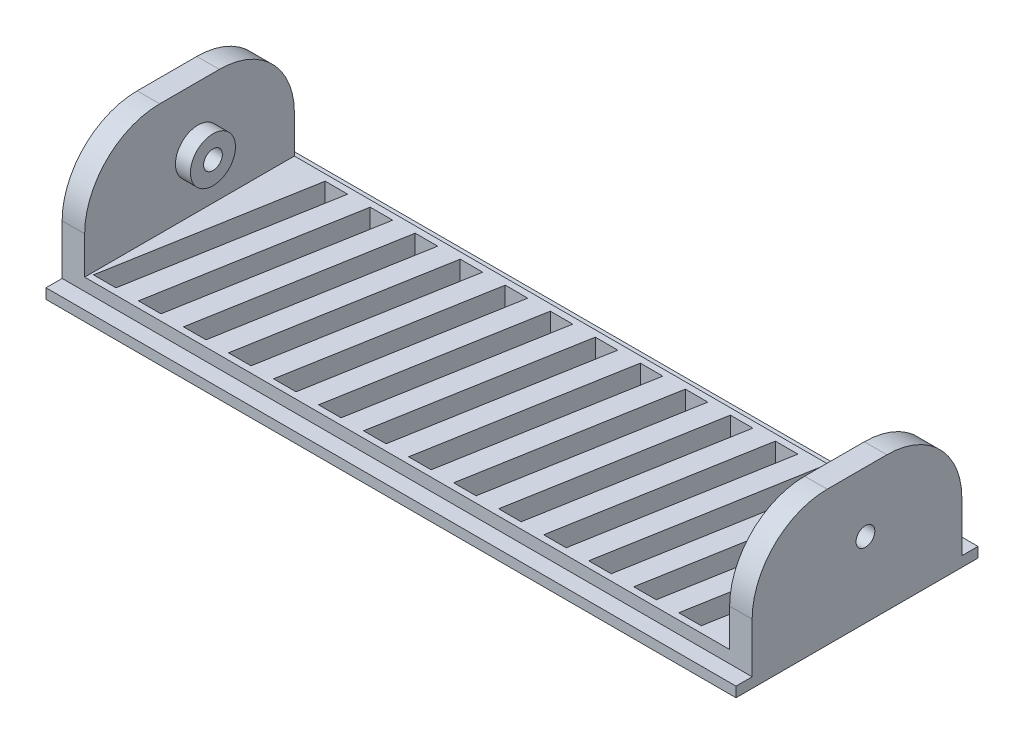
from build123d import *

# Parameters (mm, degrees)
SKETCH1_W               = 91.95
SKETCH1_H               = 32.25
BOSS_EXTRUDE1_DEPTH     = 3
SKETCH2_W               = 91.95
SKETCH2_H               = 2.15
CUT_EXTRUDE1_DEPTH      = 1.65
SKETCH4_W               = 3
SKETCH4_H               = 27.95
BOSS_EXTRUDE2_DEPTH     = 15
SKETCH5_R               = 1.25
CUT_EXTRUDE2_DEPTH      = 1
CUT_EXTRUDE2_DEPTH_BACK = 92.95
FILLET2_R               = 10
CUT_EXTRUDE5_REACH      = 20
SKETCH8_R               = 3
BOSS_EXTRUDE3_DEPTH     = 2
SKETCH9_R               = 1.25
CUT_EXTRUDE6_DEPTH      = 1
CUT_EXTRUDE6_DEPTH_BACK = 92.95


with BuildPart() as part:
    # Sketch1 → Boss-Extrude1 (new body)
    with BuildSketch(Plane(origin=(0, 0, 0), x_dir=(1, 0, 0), z_dir=(0, 1, 0))):
        with Locations((45.975, 16.125)):
            Rectangle(SKETCH1_W, SKETCH1_H)
    extrude(amount=BOSS_EXTRUDE1_DEPTH)

    # Sketch2 → Cut-Extrude1 (cut)
    with BuildSketch(Plane(origin=(0, 3, 0), x_dir=(1, 0, 0), z_dir=(0, 1, 0))):
        with Locations((45.975, 31.175)):
            Rectangle(SKETCH2_W, SKETCH2_H)
        with Locations((45.975, 1.075)):
            Rectangle(SKETCH2_W, SKETCH2_H)
    extrude(amount=-CUT_EXTRUDE1_DEPTH, mode=Mode.SUBTRACT)

    # Sketch4 → Boss-Extrude2 (add)
    with BuildSketch(Plane(origin=(0, 3, 0), x_dir=(1, 0, 0), z_dir=(0, 1, 0))):
        with Locations((1.5, 16.125)):
            Rectangle(SKETCH4_W, SKETCH4_H)
        with Locations((90.45, 16.125)):
            Rectangle(SKETCH4_W, SKETCH4_H)
    extrude(amount=BOSS_EXTRUDE2_DEPTH)

    # Sketch5 → Cut-Extrude2 (cut, two sides)
    with BuildSketch(Plane.ZY) as cut_extrude2_sk:
        with Locations((-17.25, 10)):
            Circle(SKETCH5_R)
    extrude(amount=CUT_EXTRUDE2_DEPTH, mode=Mode.SUBTRACT)
    extrude(cut_extrude2_sk.sketch, amount=-CUT_EXTRUDE2_DEPTH_BACK, mode=Mode.SUBTRACT)

    # Fillet2
    fillet2_edges = [part.edges().sort_by_distance(p)[0] for p in [
        (1.5, 18, -2.15),
        (1.5, 18, -30.1),
        (90.45, 18, -30.1),
        (90.45, 18, -2.15),
    ]]
    fillet(fillet2_edges, radius=FILLET2_R)

    # Sketch7 → Cut-Extrude5 (cut, up to next)
    with BuildSketch(Plane.XZ, mode=Mode.PRIVATE) as cut_extrude5_sk1:
        Polygon((7.95, -29.25), (10.95, -29.25), (6.321416756, -3), (3.321416756, -3), align=None)
    cut_extrude5_tool1 = extrude(cut_extrude5_sk1.sketch, amount=-CUT_EXTRUDE5_REACH, mode=Mode.PRIVATE) & part.part
    add(cut_extrude5_tool1.solids().sort_by_distance((7.135708, 0, -16.125))[0], mode=Mode.SUBTRACT)
    # Sketch7 → Cut-Extrude5 (cut, up to next)
    with BuildSketch(Plane.XZ, mode=Mode.PRIVATE) as cut_extrude5_sk2:
        Polygon((19.95, -29.25), (22.95, -29.25), (18.321416756, -3), (15.321416756, -3), align=None)
    cut_extrude5_tool2 = extrude(cut_extrude5_sk2.sketch, amount=-CUT_EXTRUDE5_REACH, mode=Mode.PRIVATE) & part.part
    add(cut_extrude5_tool2.solids().sort_by_distance((19.135708, 0, -16.125))[0], mode=Mode.SUBTRACT)
    # Sketch7 → Cut-Extrude5 (cut, up to next)
    with BuildSketch(Plane.XZ, mode=Mode.PRIVATE) as cut_extrude5_sk3:
        Polygon((25.95, -29.25), (28.95, -29.25), (24.321416756, -3), (21.321416756, -3), align=None)
    cut_extrude5_tool3 = extrude(cut_extrude5_sk3.sketch, amount=-CUT_EXTRUDE5_REACH, mode=Mode.PRIVATE) & part.part
    add(cut_extrude5_tool3.solids().sort_by_distance((25.135708, 0, -16.125))[0], mode=Mode.SUBTRACT)
    # Sketch7 → Cut-Extrude5 (cut, up to next)
    with BuildSketch(Plane.XZ, mode=Mode.PRIVATE) as cut_extrude5_sk4:
        Polygon((31.95, -29.25), (34.95, -29.25), (30.321416756, -3), (27.321416756, -3), align=None)
    cut_extrude5_tool4 = extrude(cut_extrude5_sk4.sketch, amount=-CUT_EXTRUDE5_REACH, mode=Mode.PRIVATE) & part.part
    add(cut_extrude5_tool4.solids().sort_by_distance((31.135708, 0, -16.125))[0], mode=Mode.SUBTRACT)
    # Sketch7 → Cut-Extrude5 (cut, up to next)
    with BuildSketch(Plane.XZ, mode=Mode.PRIVATE) as cut_extrude5_sk5:
        Polygon((37.95, -29.25), (40.95, -29.25), (36.321416756, -3), (33.321416756, -3), align=None)
    cut_extrude5_tool5 = extrude(cut_extrude5_sk5.sketch, amount=-CUT_EXTRUDE5_REACH, mode=Mode.PRIVATE) & part.part
    add(cut_extrude5_tool5.solids().sort_by_distance((37.135708, 0, -16.125))[0], mode=Mode.SUBTRACT)
    # Sketch7 → Cut-Extrude5 (cut, up to next)
    with BuildSketch(Plane.XZ, mode=Mode.PRIVATE) as cut_extrude5_sk6:
        Polygon((43.95, -29.25), (46.95, -29.25), (42.321416756, -3), (39.321416756, -3), align=None)
    cut_extrude5_tool6 = extrude(cut_extrude5_sk6.sketch, amount=-CUT_EXTRUDE5_REACH, mode=Mode.PRIVATE) & part.part
    add(cut_extrude5_tool6.solids().sort_by_distance((43.135708, 0, -16.125))[0], mode=Mode.SUBTRACT)
    # Sketch7 → Cut-Extrude5 (cut, up to next)
    with BuildSketch(Plane.XZ, mode=Mode.PRIVATE) as cut_extrude5_sk7:
        Polygon((55.95, -29.25), (58.95, -29.25), (54.321416756, -3), (51.321416756, -3), align=None)
    cut_extrude5_tool7 = extrude(cut_extrude5_sk7.sketch, amount=-CUT_EXTRUDE5_REACH, mode=Mode.PRIVATE) & part.part
    add(cut_extrude5_tool7.solids().sort_by_distance((55.135708, 0, -16.125))[0], mode=Mode.SUBTRACT)
    # Sketch7 → Cut-Extrude5 (cut, up to next)
    with BuildSketch(Plane.XZ, mode=Mode.PRIVATE) as cut_extrude5_sk8:
        Polygon((67.95, -29.25), (70.95, -29.25), (66.321416756, -3), (63.321416756, -3), align=None)
    cut_extrude5_tool8 = extrude(cut_extrude5_sk8.sketch, amount=-CUT_EXTRUDE5_REACH, mode=Mode.PRIVATE) & part.part
    add(cut_extrude5_tool8.solids().sort_by_distance((67.135708, 0, -16.125))[0], mode=Mode.SUBTRACT)
    # Sketch7 → Cut-Extrude5 (cut, up to next)
    with BuildSketch(Plane.XZ, mode=Mode.PRIVATE) as cut_extrude5_sk9:
        Polygon((79.95, -29.25), (75.321416756, -3), (78.321416756, -3), (82.95, -29.25), align=None)
    cut_extrude5_tool9 = extrude(cut_extrude5_sk9.sketch, amount=-CUT_EXTRUDE5_REACH, mode=Mode.PRIVATE) & part.part
    add(cut_extrude5_tool9.solids().sort_by_distance((79.135708, 0, -16.125))[0], mode=Mode.SUBTRACT)
    # Sketch7 → Cut-Extrude5 (cut, up to next)
    with BuildSketch(Plane.XZ, mode=Mode.PRIVATE) as cut_extrude5_sk10:
        Polygon((88.95, -29.25), (84.321416756, -3), (81.321416756, -3), (85.95, -29.25), align=None)
    cut_extrude5_tool10 = extrude(cut_extrude5_sk10.sketch, amount=-CUT_EXTRUDE5_REACH, mode=Mode.PRIVATE) & part.part
    add(cut_extrude5_tool10.solids().sort_by_distance((85.135708, 0, -16.125))[0], mode=Mode.SUBTRACT)
    # Sketch7 → Cut-Extrude5 (cut, up to next)
    with BuildSketch(Plane.XZ, mode=Mode.PRIVATE) as cut_extrude5_sk11:
        Polygon((16.95, -29.25), (12.321416756, -3), (9.321416756, -3), (13.95, -29.25), align=None)
    cut_extrude5_tool11 = extrude(cut_extrude5_sk11.sketch, amount=-CUT_EXTRUDE5_REACH, mode=Mode.PRIVATE) & part.part
    add(cut_extrude5_tool11.solids().sort_by_distance((13.135708, 0, -16.125))[0], mode=Mode.SUBTRACT)
    # Sketch7 → Cut-Extrude5 (cut, up to next)
    with BuildSketch(Plane.XZ, mode=Mode.PRIVATE) as cut_extrude5_sk12:
        Polygon((49.95, -29.25), (45.321416756, -3), (48.321416756, -3), (52.95, -29.25), align=None)
    cut_extrude5_tool12 = extrude(cut_extrude5_sk12.sketch, amount=-CUT_EXTRUDE5_REACH, mode=Mode.PRIVATE) & part.part
    add(cut_extrude5_tool12.solids().sort_by_distance((49.135708, 0, -16.125))[0], mode=Mode.SUBTRACT)
    # Sketch7 → Cut-Extrude5 (cut, up to next)
    with BuildSketch(Plane.XZ, mode=Mode.PRIVATE) as cut_extrude5_sk13:
        Polygon((61.95, -29.25), (57.321416756, -3), (60.321416756, -3), (64.95, -29.25), align=None)
    cut_extrude5_tool13 = extrude(cut_extrude5_sk13.sketch, amount=-CUT_EXTRUDE5_REACH, mode=Mode.PRIVATE) & part.part
    add(cut_extrude5_tool13.solids().sort_by_distance((61.135708, 0, -16.125))[0], mode=Mode.SUBTRACT)
    # Sketch7 → Cut-Extrude5 (cut, up to next)
    with BuildSketch(Plane.XZ, mode=Mode.PRIVATE) as cut_extrude5_sk14:
        Polygon((73.95, -29.25), (69.321416756, -3), (72.321416756, -3), (76.95, -29.25), align=None)
    cut_extrude5_tool14 = extrude(cut_extrude5_sk14.sketch, amount=-CUT_EXTRUDE5_REACH, mode=Mode.PRIVATE) & part.part
    add(cut_extrude5_tool14.solids().sort_by_distance((73.135708, 0, -16.125))[0], mode=Mode.SUBTRACT)

    # Sketch8 → Boss-Extrude3 (add)
    with BuildSketch(Plane(origin=(3, 0, 0), x_dir=(0, 0, -1), z_dir=(1, 0, 0))):
        with Locations((17.25, 10)):
            Circle(SKETCH8_R)
    boss_extrude3 = extrude(amount=BOSS_EXTRUDE3_DEPTH)

    # Mirror1: Boss-Extrude3 across plane
    add(boss_extrude3.mirror(Plane(origin=(45.975, 0, 0), x_dir=(0, 0, 1), z_dir=(1, 0, 0))))

    # Sketch9 → Cut-Extrude6 (cut, two sides)
    with BuildSketch(Plane.ZY) as cut_extrude6_sk:
        with Locations((-17.25, 10)):
            Circle(SKETCH9_R)
    extrude(amount=CUT_EXTRUDE6_DEPTH, mode=Mode.SUBTRACT)
    extrude(cut_extrude6_sk.sketch, amount=-CUT_EXTRUDE6_DEPTH_BACK, mode=Mode.SUBTRACT)


solid = part.part
